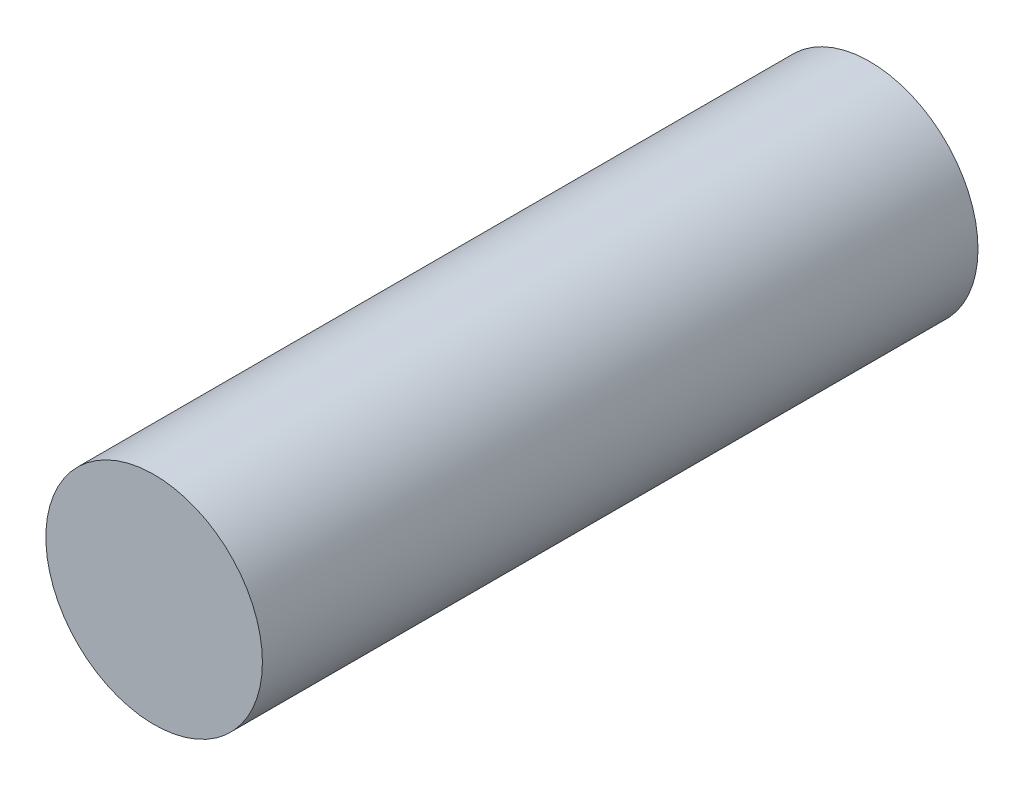
from build123d import *

# Parameters (mm, degrees)
SKETCH1_R           = 18.25625
BOSS_EXTRUDE1_DEPTH = 60.325


with BuildPart() as part:
    # Sketch1 → Boss-Extrude1 (new body, symmetric)
    with BuildSketch(Plane.XY):
        Circle(SKETCH1_R)
    extrude(amount=BOSS_EXTRUDE1_DEPTH, both=True)


solid = part.part
